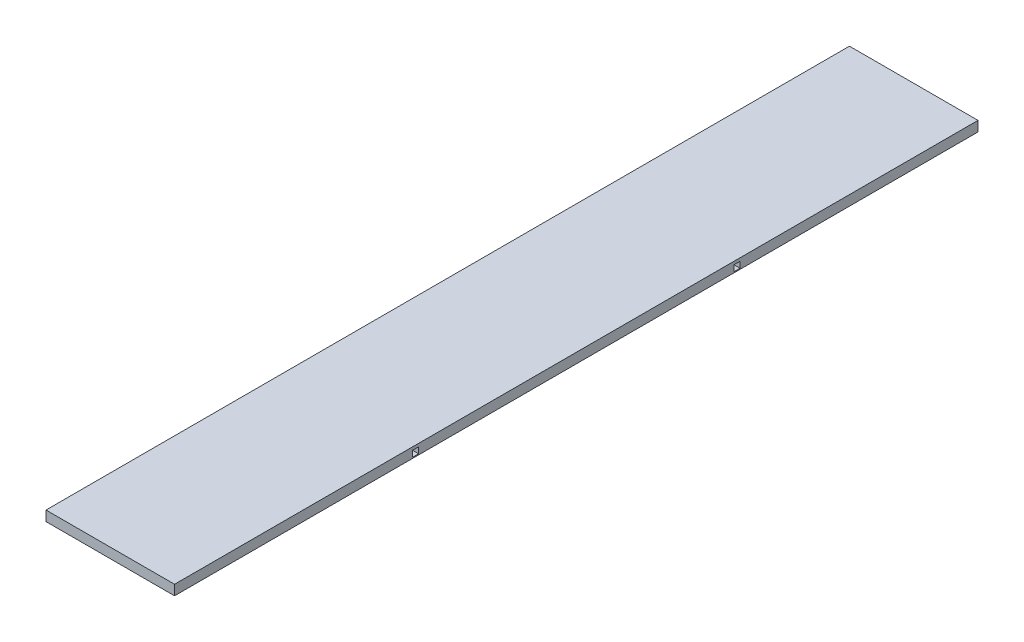
from build123d import *

# Parameters (mm, degrees)
SKETCH1_W           = 406.4
SKETCH1_H           = 2540
BOSS_EXTRUDE1_DEPTH = 31.75
SKETCH2_W           = 19.05
SKETCH2_H           = 19.05
CUT_EXTRUDE1_DEPTH  = 406.4


with BuildPart() as part:
    # Sketch1 → Boss-Extrude1 (new body)
    with BuildSketch(Plane(origin=(0, 0, 0), x_dir=(1, 0, 0), z_dir=(0, 1, 0))):
        Rectangle(SKETCH1_W, SKETCH1_H)
    extrude(amount=BOSS_EXTRUDE1_DEPTH)

    # Sketch2 → Cut-Extrude1 (cut)
    with BuildSketch(Plane(origin=(203.2, 0, 0), x_dir=(0, 0, -1), z_dir=(1, 0, 0))):
        with Locations((-508, 12.7)):
            Rectangle(SKETCH2_W, SKETCH2_H)
        with Locations((508, 12.7)):
            Rectangle(SKETCH2_W, SKETCH2_H)
    extrude(amount=-CUT_EXTRUDE1_DEPTH, mode=Mode.SUBTRACT)


solid = part.part
